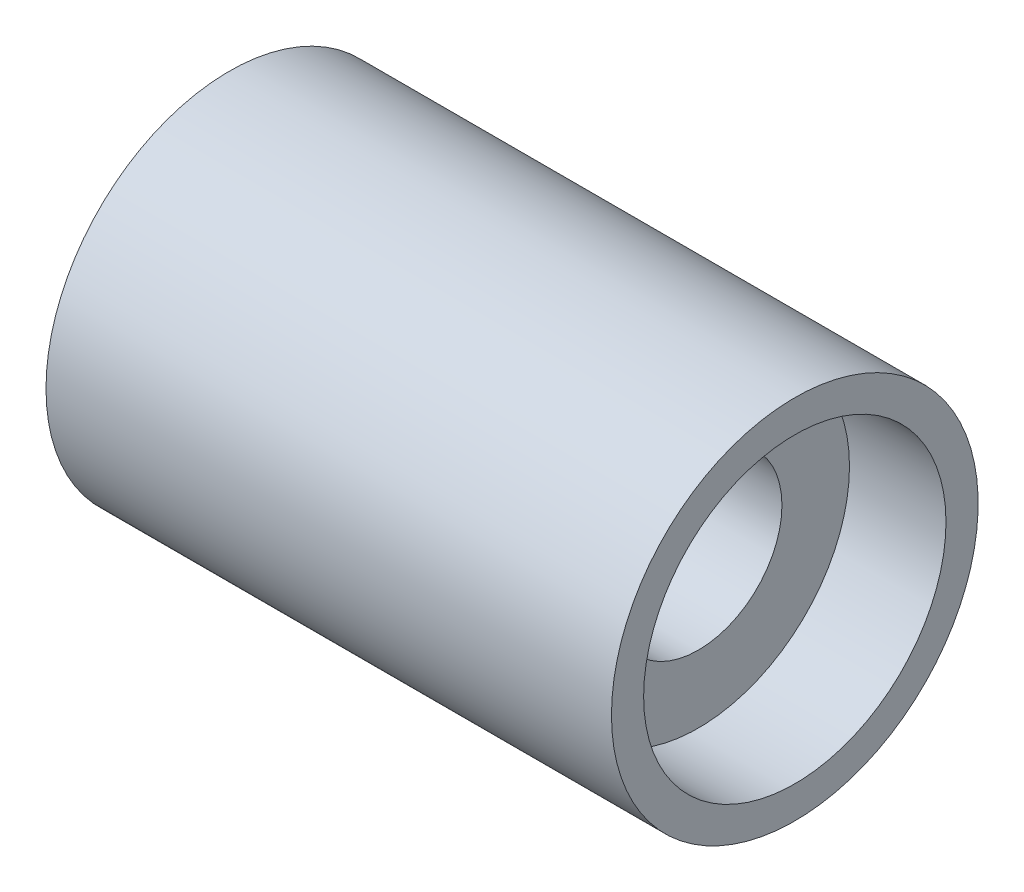
from build123d import *


with BuildPart() as part:
    # Esquisse1 → Révolution1 (revolve)
    with BuildSketch(Plane.XY, mode=Mode.PRIVATE) as r_volution1_sk:
        Polygon((28.95, 13), (28.95, 23.5), (43.95, 23.5), (43.95, 28.5), (-43.95, 28.5), (-43.95, 23.5), (-28.95, 23.5), (-28.95, 13), align=None)
    revolve(r_volution1_sk.sketch.rotate(Axis((-28.010573724, 0, 0), (1, 0, 0)), 90), axis=Axis((-28.010573724, 0, 0), (1, 0, 0)))  # turned: the seam where the file's is


solid = part.part
